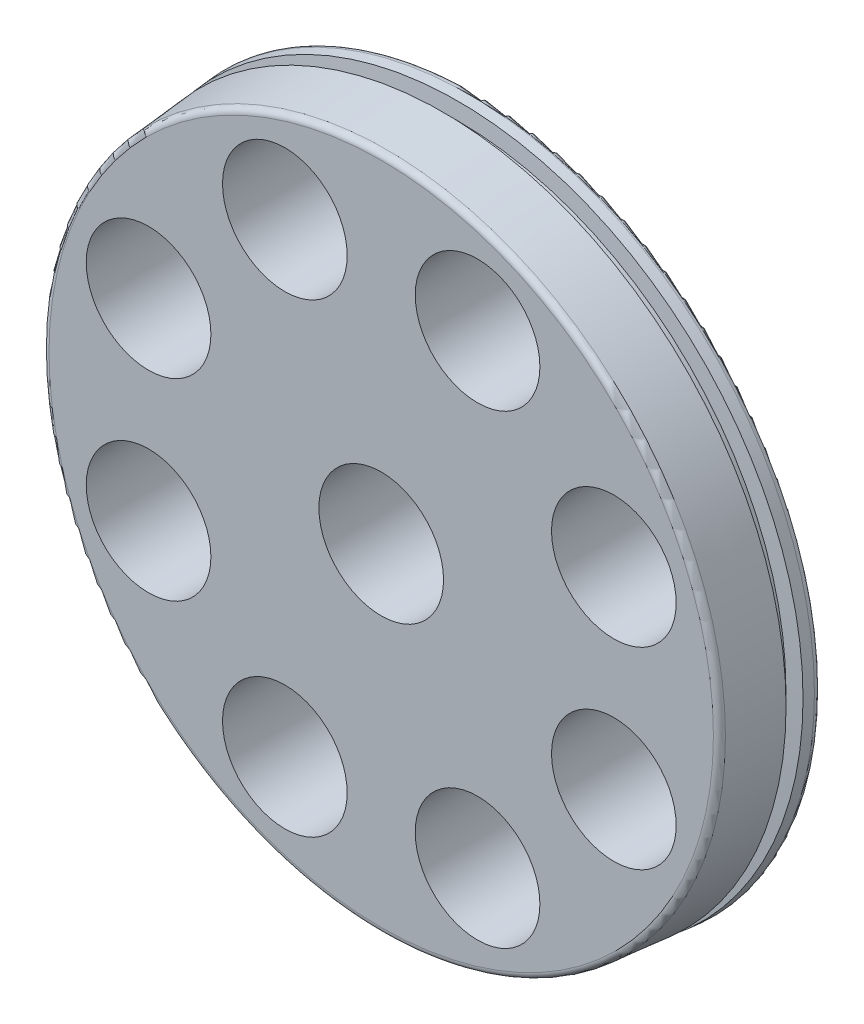
from build123d import *

# Parameters (mm, degrees)
SKETCH1_R           = 69.85
BOSS_EXTRUDE1_DEPTH = 19.05
BOSS_EXTRUDE1_TAPER = 5
FILLET2_R           = 1.27
SKETCH3_R           = 12.573
CUT_EXTRUDE1_DEPTH  = 19.05


with BuildPart() as part:
    # Sketch1 → Boss-Extrude1 (new body)
    with BuildSketch(Plane.XY):
        Circle(SKETCH1_R)
    extrude(amount=BOSS_EXTRUDE1_DEPTH, taper=BOSS_EXTRUDE1_TAPER)

    # Fillet2
    fillet2_edges = [part.edges().sort_by_distance(p)[0] for p in [
        (-69.85, 0, 0),
        (-68.18334096, 0, 19.05),
    ]]
    fillet(fillet2_edges, radius=FILLET2_R)

    # Sketch2 → Cut-Revolve1 (revolve, cut)
    with BuildSketch(Plane(origin=(0, 0, 0), x_dir=(1, 0, 0), z_dir=(0, 1, 0))):
        Polygon((-66.369445843, -3.770276507), (-66.369445843, -6.389723493), (-69.544445843, -6.6675), (-69.544445843, -3.4925), align=None)
    revolve(axis=Axis((0, 0, 0), (0, 0, 1)), mode=Mode.SUBTRACT)

    # Sketch3 → Cut-Extrude1 (cut)
    with BuildSketch(Plane(origin=(0, 0, 0), x_dir=(-1, 0, 0), z_dir=(0, 0, -1))):
        with Locations((-19.440318364, 46.933080252)):
            Circle(SKETCH3_R)
        with Locations((19.440318364, 46.933080252)):
            Circle(SKETCH3_R)
        with Locations((46.933080252, 19.440318364)):
            Circle(SKETCH3_R)
        with Locations((46.933080252, -19.440318364)):
            Circle(SKETCH3_R)
        with Locations((19.440318364, -46.933080252)):
            Circle(SKETCH3_R)
        with Locations((-19.440318364, -46.933080252)):
            Circle(SKETCH3_R)
        with Locations((-46.933080252, -19.440318364)):
            Circle(SKETCH3_R)
        with Locations((-46.933080252, 19.440318364)):
            Circle(SKETCH3_R)
        Circle(SKETCH3_R)
    extrude(amount=-CUT_EXTRUDE1_DEPTH, mode=Mode.SUBTRACT)


solid = part.part
